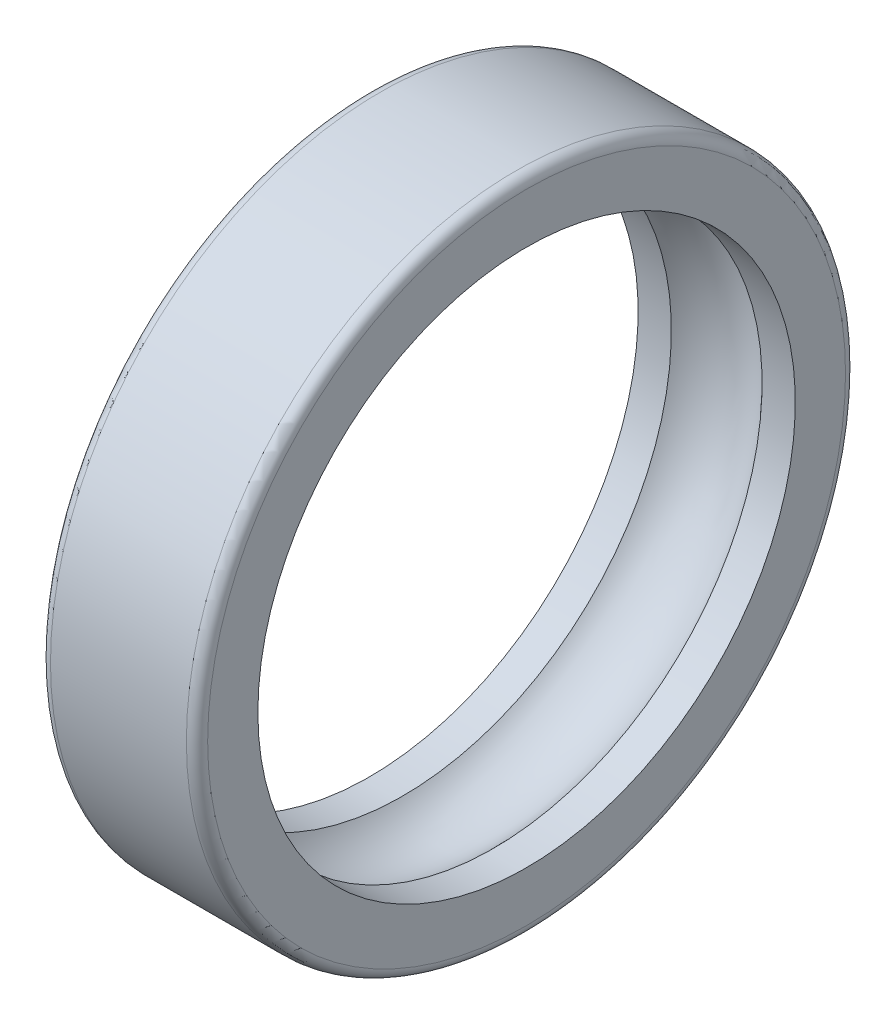
from build123d import *

# Parameters (mm, degrees)
FILLET1_R = 2.1


with BuildPart() as part:
    # Sketch1 → Revolve1 (revolve)
    with BuildSketch(Plane.XY):
        with BuildLine():
            Line((-15.5, 65), (15.5, 65))
            Line((15.5, 65), (15.5, 53))
            Line((15.5, 53), (8.94427191, 53))
            ThreePointArc((8.94427191, 53), (0, 57), (-8.94427191, 53))
            Line((-8.94427191, 53), (-15.5, 53))
            Line((-15.5, 53), (-15.5, 65))
        make_face()
    revolve(axis=Axis((-20.252619606, 0, 0), (1, 0, 0)))

    # Fillet1
    fillet1_edges = [part.edges().sort_by_distance(p)[0] for p in [
        (-15.5, -65, 0),
        (15.5, -65, 0),
    ]]
    fillet(fillet1_edges, radius=FILLET1_R)


solid = part.part
